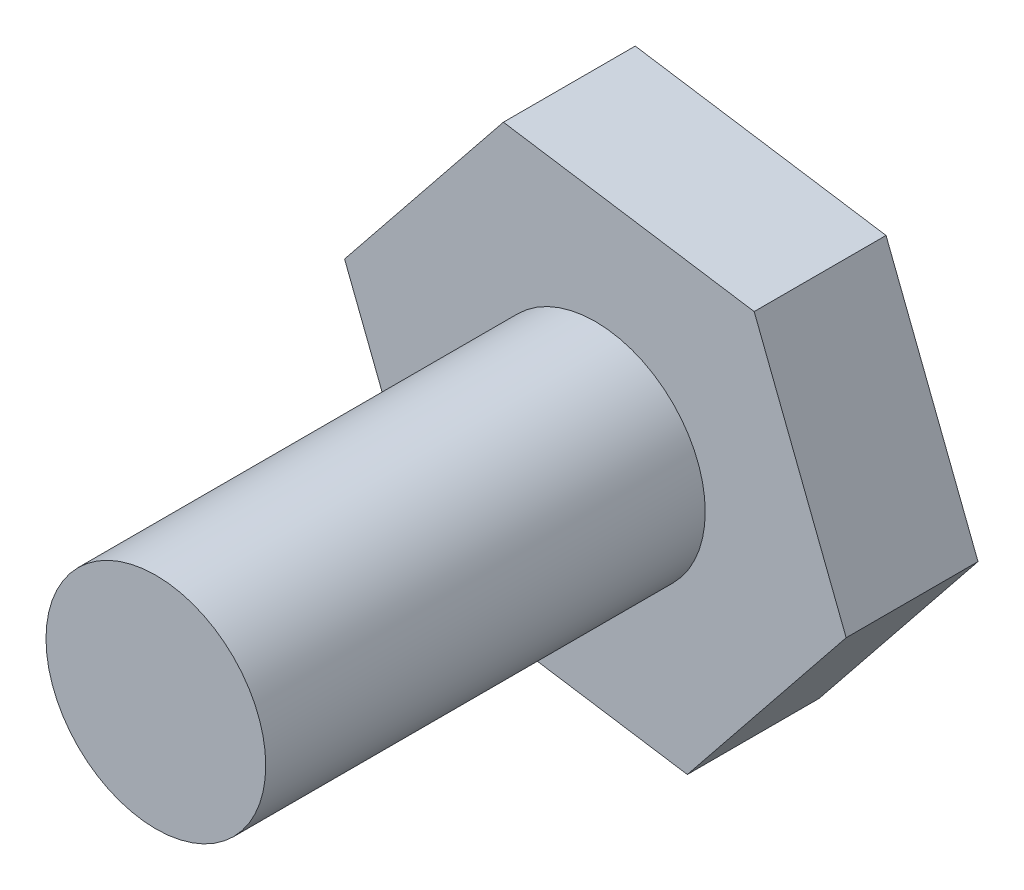
from build123d import *

# Parameters (mm, degrees)
SALIENTE_EXTRUIR3_DEPTH = 3
CROQUIS3_R              = 2.5
SALIENTE_EXTRUIR4_DEPTH = 13


with BuildPart() as part:
    # Croquis1 → Saliente-Extruir3 (new body)
    with BuildSketch(Plane.XY):
        Polygon((-54.386636348, 4.299863782), (-50.772905222, 8.802560828), (-52.865489687, 14.183492308), (-58.571805277, 15.061726742), (-62.185536402, 10.559029696), (-60.092951938, 5.178098216), align=None)
    extrude(amount=SALIENTE_EXTRUIR3_DEPTH)

    # Croquis3 → Saliente-Extruir4 (add)
    with BuildSketch(Plane.XY):
        with Locations((-56.479220812, 9.680795262)):
            Circle(CROQUIS3_R)
    extrude(amount=SALIENTE_EXTRUIR4_DEPTH)


solid = part.part
